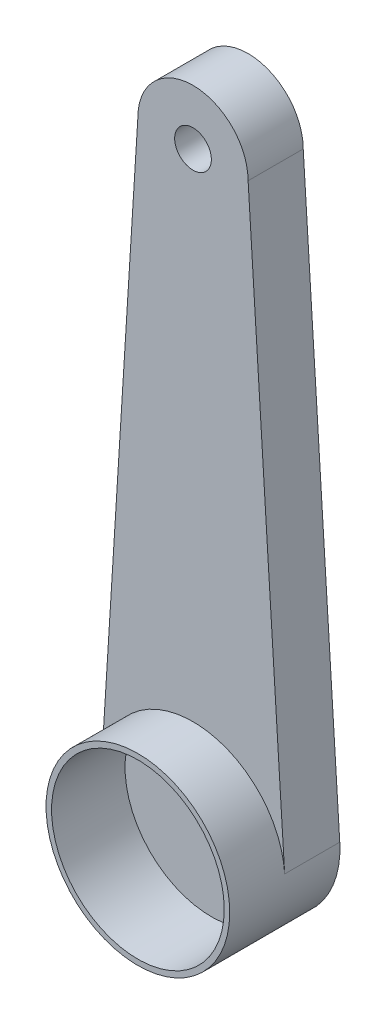
from build123d import *

# Parameters (mm, degrees)
BOSS_EXTRUDE1_DEPTH = 1.5
SKETCH2_R           = 2.5
BOSS_EXTRUDE2_DEPTH = 1.5
SKETCH3_R           = 2.35
CUT_EXTRUDE1_DEPTH  = 2
SKETCH4_R           = 0.5
CUT_EXTRUDE2_DEPTH  = 2


with BuildPart() as part:
    # Sketch1 → Boss-Extrude1 (new body)
    with BuildSketch(Plane.XY):
        with BuildLine():
            Line((-1.5, 16), (-2.495083503, 0.156710922))
            ThreePointArc((-2.495083503, 0.156710922), (0, -2.5), (2.495083503, 0.156710922))
            Line((2.495083503, 0.156710922), (1.5, 16))
            ThreePointArc((1.5, 16), (0, 17.5), (-1.5, 16))
        make_face()
    extrude(amount=BOSS_EXTRUDE1_DEPTH)

    # Sketch2 → Boss-Extrude2 (add)
    with BuildSketch(Plane.XY.offset(1.5)):
        Circle(SKETCH2_R)
    extrude(amount=BOSS_EXTRUDE2_DEPTH)

    # Sketch3 → Cut-Extrude1 (cut)
    with BuildSketch(Plane.XY.offset(3)):
        Circle(SKETCH3_R)
    extrude(amount=-CUT_EXTRUDE1_DEPTH, mode=Mode.SUBTRACT)

    # Sketch4 → Cut-Extrude2 (cut)
    with BuildSketch(Plane.XY.offset(1.5)):
        with Locations((0, 16)):
            Circle(SKETCH4_R)
    extrude(amount=-CUT_EXTRUDE2_DEPTH, mode=Mode.SUBTRACT)


solid = part.part
